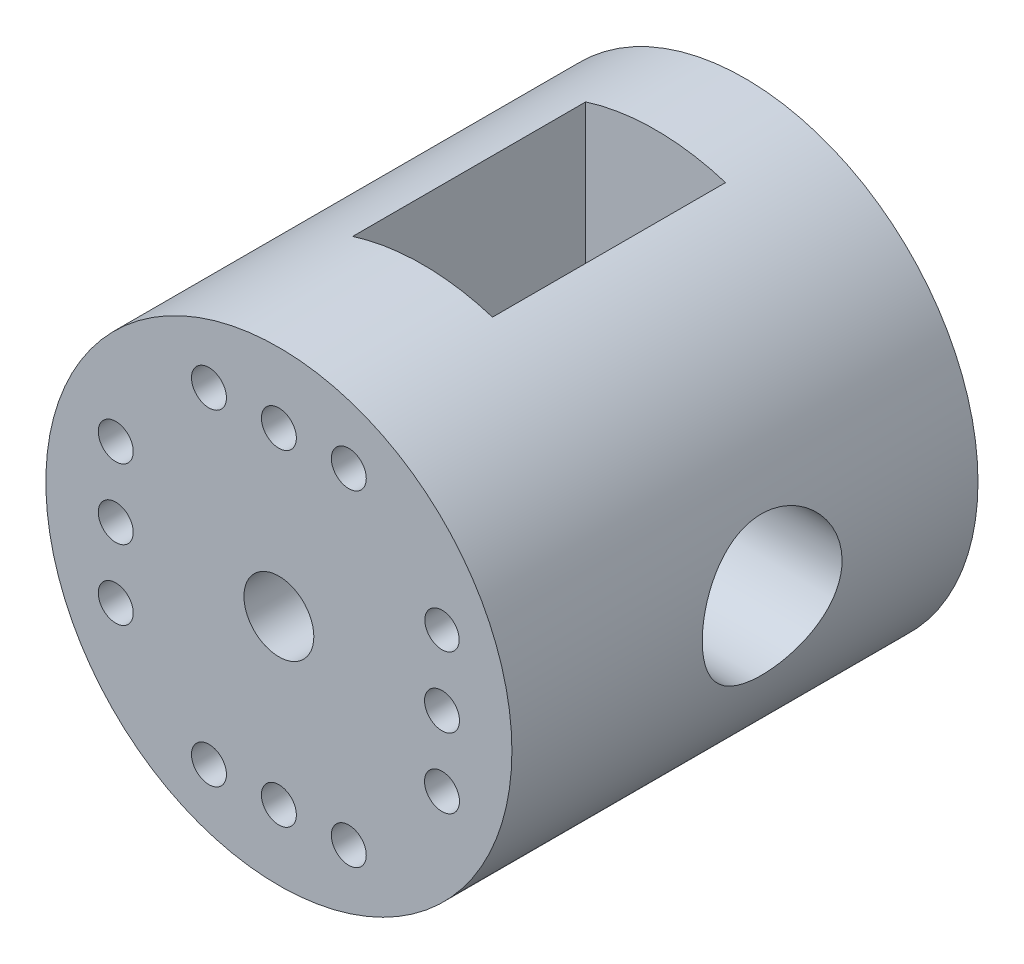
from build123d import *

# Parameters (mm, degrees)
SKETCH2_R               = 10
SKETCH2_R_2             = 1.5
SKETCH2_R_3             = 0.736643129
SKETCH2_R_4             = 0.75
BOSS_EXTRUDE1_DEPTH     = 5
BOSS_EXTRUDE2_START     = -15
SKETCH3_R               = 10
BOSS_EXTRUDE2_DEPTH     = 15
CUT_EXTRUDE1_DEPTH      = 20
CUT_EXTRUDE1_DEPTH_BACK = 20
SKETCH4_W               = 6
SKETCH4_H               = 10
CUT_EXTRUDE2_DEPTH      = 20
CUT_EXTRUDE2_DEPTH_BACK = 20
SKETCH5_R               = 3


with BuildPart() as part:
    # Sketch2 → Boss-Extrude1 (new body)
    with BuildSketch(Plane.XY):
        Circle(SKETCH2_R)
        Circle(SKETCH2_R_2, mode=Mode.SUBTRACT)
        with Locations((7, 3)):
            Circle(SKETCH2_R_3, mode=Mode.SUBTRACT)
        with Locations((7, 0)):
            Circle(SKETCH2_R_4, mode=Mode.SUBTRACT)
        with Locations((7, -3)):
            Circle(SKETCH2_R_4, mode=Mode.SUBTRACT)
        with Locations((3, -7)):
            Circle(SKETCH2_R_4, mode=Mode.SUBTRACT)
        with Locations((0, -7)):
            Circle(SKETCH2_R_4, mode=Mode.SUBTRACT)
        with Locations((-3, -7)):
            Circle(SKETCH2_R_4, mode=Mode.SUBTRACT)
        with Locations((-7, -3)):
            Circle(SKETCH2_R_4, mode=Mode.SUBTRACT)
        with Locations((-7, 0)):
            Circle(SKETCH2_R_4, mode=Mode.SUBTRACT)
        with Locations((-7, 3)):
            Circle(SKETCH2_R_4, mode=Mode.SUBTRACT)
        with Locations((-3, 7)):
            Circle(SKETCH2_R_4, mode=Mode.SUBTRACT)
        with Locations((0, 7)):
            Circle(SKETCH2_R_4, mode=Mode.SUBTRACT)
        with Locations((3, 7)):
            Circle(SKETCH2_R_4, mode=Mode.SUBTRACT)
    extrude(amount=BOSS_EXTRUDE1_DEPTH)

    # Sketch3 → Boss-Extrude2 (add)
    with BuildSketch(Plane.XY.offset(BOSS_EXTRUDE2_START)):
        Circle(SKETCH3_R)
    extrude(amount=BOSS_EXTRUDE2_DEPTH)

    # Sketch4 → Cut-Extrude1 (cut, two sides: drawn at the far end of the back side and taken through both)
    with BuildSketch(Plane(origin=(0, 0, 0), x_dir=(1, 0, 0), z_dir=(0, 1, 0)).offset(-CUT_EXTRUDE1_DEPTH_BACK)):
        with Locations((0, 6.167476411)):
            Rectangle(SKETCH4_W, SKETCH4_H)
    extrude(amount=CUT_EXTRUDE1_DEPTH + CUT_EXTRUDE1_DEPTH_BACK, mode=Mode.SUBTRACT)

    # Sketch5 → Cut-Extrude2 (cut, two sides: drawn at the far end of the back side and taken through both)
    with BuildSketch(Plane(origin=(0, 0, 0), x_dir=(0, 0, -1), z_dir=(1, 0, 0)).offset(-CUT_EXTRUDE2_DEPTH_BACK)):
        with Locations((6.167476411, 0)):
            Circle(SKETCH5_R)
    extrude(amount=CUT_EXTRUDE2_DEPTH + CUT_EXTRUDE2_DEPTH_BACK, mode=Mode.SUBTRACT)


solid = part.part
